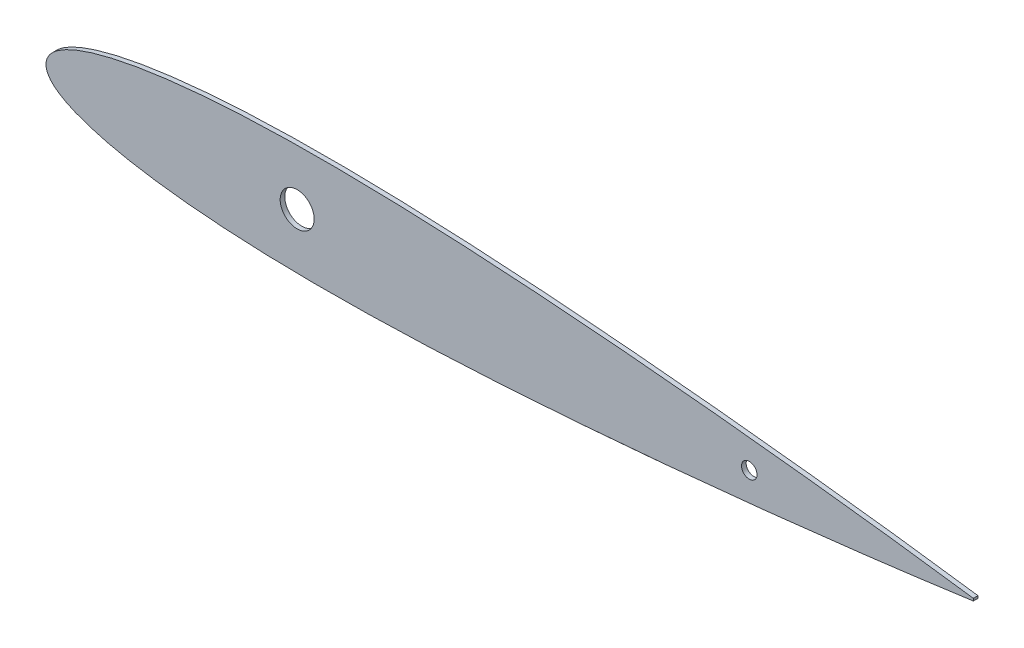
from build123d import *

# Parameters (mm, degrees)
BOSS_EXTRUDE1_DEPTH = 1.5
SKETCH7_R           = 5.5
SKETCH7_R_2         = 2.5
CUT_EXTRUDE7_DEPTH  = 2.5000001


with BuildPart() as part:
    # Sketch5 → Boss-Extrude1 (new body)
    with BuildSketch(Plane.XY):
        with BuildLine():
            Line((300, 0.378000086), (300, -0.378000086))
            add(Edge.make_bspline(
                [(300, 0.378000086), (299.270406258, 0.479445931), (297.234666467, 0.762503927), (293.659648722, 1.257673791), (289.112409325, 1.874242868), (284.080813047, 2.544518018), (278.752039398, 3.238123051), (273.265892957, 3.934947328), (267.705948145, 4.629020993), (262.114554424, 5.313070312), (256.508339042, 5.98219317), (250.891727853, 6.637992315), (245.269544548, 7.281780887), (239.647331656, 7.912234559), (234.025115138, 8.526993981), (228.399071658, 9.126231834), (222.768240123, 9.71307981), (217.135901993, 10.287462144), (211.505390076, 10.846943545), (205.877598449, 11.391645411), (200.251489743, 11.920887329), (194.626396629, 12.434619899), (189.002771954, 12.931914744), (183.381504479, 13.413100625), (177.763197883, 13.876379849), (172.148272526, 14.321240443), (166.537499181, 14.747824264), (160.931704642, 15.154231582), (155.331676028, 15.539104381), (149.737504253, 15.902653172), (144.148652919, 16.241849804), (138.565642978, 16.557424303), (132.990821912, 16.847401378), (127.427400287, 17.110215561), (121.877579225, 17.343895653), (116.340716908, 17.545260794), (110.81543346, 17.712683139), (105.301229225, 17.844501987), (99.800524694, 17.940095883), (94.317389178, 17.996594522), (88.855716162, 18.010128544), (83.418598836, 17.97923792), (78.008430461, 17.899164774), (72.628403778, 17.767037818), (67.282685946, 17.579417922), (61.977310891, 17.331519421), (56.72063582, 17.021036513), (51.525118947, 16.640961845), (46.408145083, 16.190192264), (41.394117392, 15.661672653), (36.515611307, 15.053967199), (31.818948595, 14.365626864), (27.366102973, 13.60347877), (23.235155161, 12.782586344), (19.502578811, 11.920253456), (16.218207008, 11.044600302), (13.389120989, 10.175078564), (10.984863761, 9.333500833), (8.961495446, 8.522064815), (7.267225637, 7.746977759), (5.845985727, 7.010627212), (4.647644075, 6.300635462), (3.62816801, 5.60651494), (2.751841757, 4.926636369), (2.006189751, 4.249918223), (1.390518388, 3.570260302), (0.900932575, 2.890942908), (0.52920759, 2.220219777), (0.260411531, 1.566459291), (0.085644609, 0.931036139), (-0.003577313, 0.308981085), (-0.003577313, -0.308981085), (0.085644609, -0.931036139), (0.260411531, -1.566459291), (0.52920759, -2.220219777), (0.900932575, -2.890942908), (1.390518388, -3.570260302), (2.006189751, -4.249918223), (2.751841757, -4.926636369), (3.62816801, -5.60651494), (4.647644075, -6.300635462), (5.845985727, -7.010627213), (7.267225637, -7.746977757), (8.961495444, -8.522064829), (10.984863772, -9.333500769), (13.389120938, -10.175078867), (16.218207245, -11.044598882), (19.502577721, -11.920259984), (23.235160006, -12.782557313), (27.366065703, -13.603599247), (31.819014163, -14.365116623), (36.515574857, -15.054109513), (41.394123531, -15.66163244), (46.408143388, -16.190203367), (51.525119412, -16.640958803), (56.720635693, -17.021037342), (61.977310926, -17.331519196), (67.282685937, -17.579417983), (72.628403781, -17.767037802), (78.008430461, -17.899164778), (83.418598837, -17.979237918), (88.855716162, -18.010128544), (94.317389178, -17.996594522), (99.800524694, -17.940095883), (105.301229225, -17.844501987), (110.81543346, -17.712683139), (116.340716908, -17.545260794), (121.877579225, -17.343895653), (127.427400287, -17.110215561), (132.990821912, -16.847401378), (138.565642978, -16.557424303), (144.148652919, -16.241849804), (149.737504253, -15.902653172), (155.331676028, -15.539104381), (160.931704642, -15.154231582), (166.537499181, -14.747824264), (172.148272526, -14.321240443), (177.763197883, -13.876379849), (183.381504479, -13.413100625), (189.002771954, -12.931914743), (194.626396629, -12.434619899), (200.251489743, -11.920887329), (205.877598449, -11.391645411), (211.505390076, -10.846943545), (217.135901993, -10.287462144), (222.768240123, -9.71307981), (228.399071658, -9.126231834), (234.025115138, -8.526993981), (239.647331656, -7.912234559), (245.269544548, -7.281780887), (250.891727853, -6.637992315), (256.508339042, -5.98219317), (262.114554424, -5.313070312), (267.705948145, -4.629020993), (273.265892957, -3.934947328), (278.752039398, -3.238123051), (284.080813047, -2.544518018), (289.112409325, -1.874242868), (293.659648722, -1.257673791), (297.234666467, -0.762503927), (299.270406258, -0.47944593), (300, -0.378000086)],
                knots=[0, 0, 0, 0, 0.003612221, 0.010078953, 0.017698618, 0.026115111, 0.034970966, 0.04405038, 0.05323433, 0.06244757, 0.071673993, 0.080921319, 0.090177538, 0.099424342, 0.108664441, 0.117912199, 0.127169502, 0.136426595, 0.145675426, 0.154916495, 0.164153237, 0.173386649, 0.182615736, 0.191838089, 0.201053134, 0.210260393, 0.219458942, 0.228646747, 0.237822316, 0.246985224, 0.256137384, 0.265279416, 0.27440695, 0.283512193, 0.292591781, 0.301646285, 0.310681793, 0.319699068, 0.32869452, 0.33766016, 0.346588583, 0.355477412, 0.364322937, 0.373121614, 0.381867635, 0.390553005, 0.399166026, 0.407689628, 0.416098119, 0.424354887, 0.432412429, 0.440204728, 0.447630505, 0.454563638, 0.460855379, 0.466413319, 0.47122861, 0.475365774, 0.47890126, 0.481915077, 0.484498872, 0.486747127, 0.488741252, 0.490543179, 0.492182104, 0.493672831, 0.495031908, 0.49627906, 0.497424737, 0.498490166, 0.499502758, 0.500497254, 0.501509846, 0.502575275, 0.503720952, 0.504968104, 0.506327181, 0.507817908, 0.509456832, 0.51125876, 0.513252884, 0.51550114, 0.518084934, 0.521098752, 0.524634237, 0.528771401, 0.533586692, 0.539144632, 0.545436374, 0.552369506, 0.5597952, 0.567587571, 0.575645113, 0.583901881, 0.592310372, 0.600833974, 0.609446995, 0.618132365, 0.626878386, 0.635677063, 0.644522588, 0.653411417, 0.66233984, 0.67130548, 0.680300932, 0.689318207, 0.698353715, 0.707408219, 0.716487807, 0.72559305, 0.734720584, 0.743862616, 0.753014776, 0.762177684, 0.771353253, 0.780541058, 0.789739607, 0.798946866, 0.808161911, 0.817384264, 0.826613351, 0.835846763, 0.845083505, 0.854324574, 0.863573405, 0.872830498, 0.882087801, 0.891335559, 0.900575658, 0.909822462, 0.919078681, 0.928326007, 0.93755243, 0.94676567, 0.95594962, 0.965029034, 0.973884889, 0.982301382, 0.989921047, 0.996387779, 1, 1, 1, 1], degree=3))
        make_face()
    extrude(amount=BOSS_EXTRUDE1_DEPTH)

    # Sketch7 → Cut-Extrude7 (cut, through all)
    with BuildSketch(Plane.XY.offset(1.5)):
        with Locations((81.25, 0)):
            Circle(SKETCH7_R)
        with Locations((227.5, 0)):
            Circle(SKETCH7_R_2)
    extrude(amount=-CUT_EXTRUDE7_DEPTH, mode=Mode.SUBTRACT)


solid = part.part
